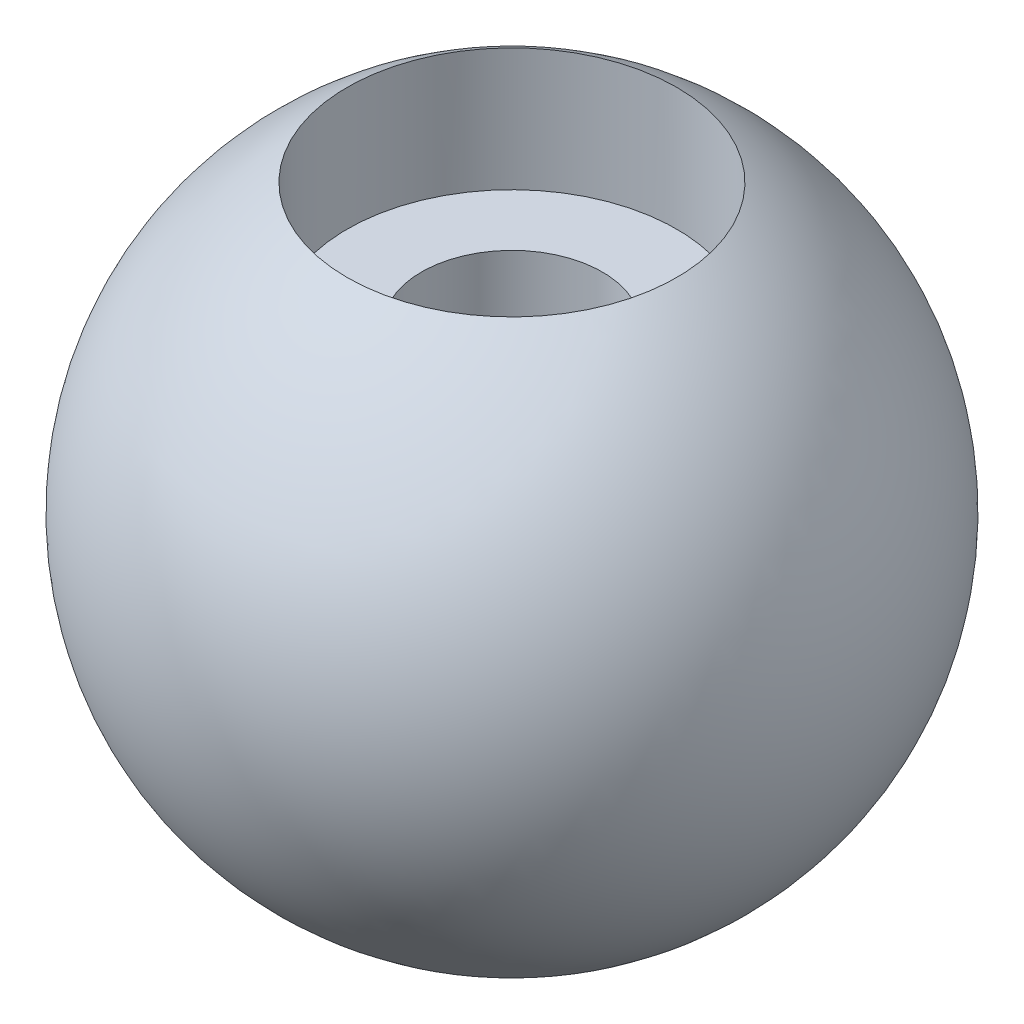
from build123d import *


with BuildPart() as part:
    # Sketch1 → Complete_Ball (revolve)
    with BuildSketch(Plane.XY):
        with BuildLine():
            Line((0, 9.525), (0, -9.525))
            ThreePointArc((0, -9.525), (9.525, 0), (0, 9.525))
        make_face()
    revolve(axis=Axis((0, 9.119269759, 0), (0, -1, 0)))

    # Sketch5 → Counterbored_hole (revolve, cut)
    with BuildSketch(Plane.XY, mode=Mode.PRIVATE) as counterbored_hole_sk:
        Polygon((2.6162, -9.525), (2.6162, 4.699), (4.7625, 4.699), (4.7625, 9.525), (0, 9.525), (0, -9.525), align=None)
    revolve(counterbored_hole_sk.sketch.rotate(Axis((0, 7.818373071, 0), (0, -1, 0)), 90), axis=Axis((0, 7.818373071, 0), (0, -1, 0)), mode=Mode.SUBTRACT)  # turned: the seam where the file's is


solid = part.part
